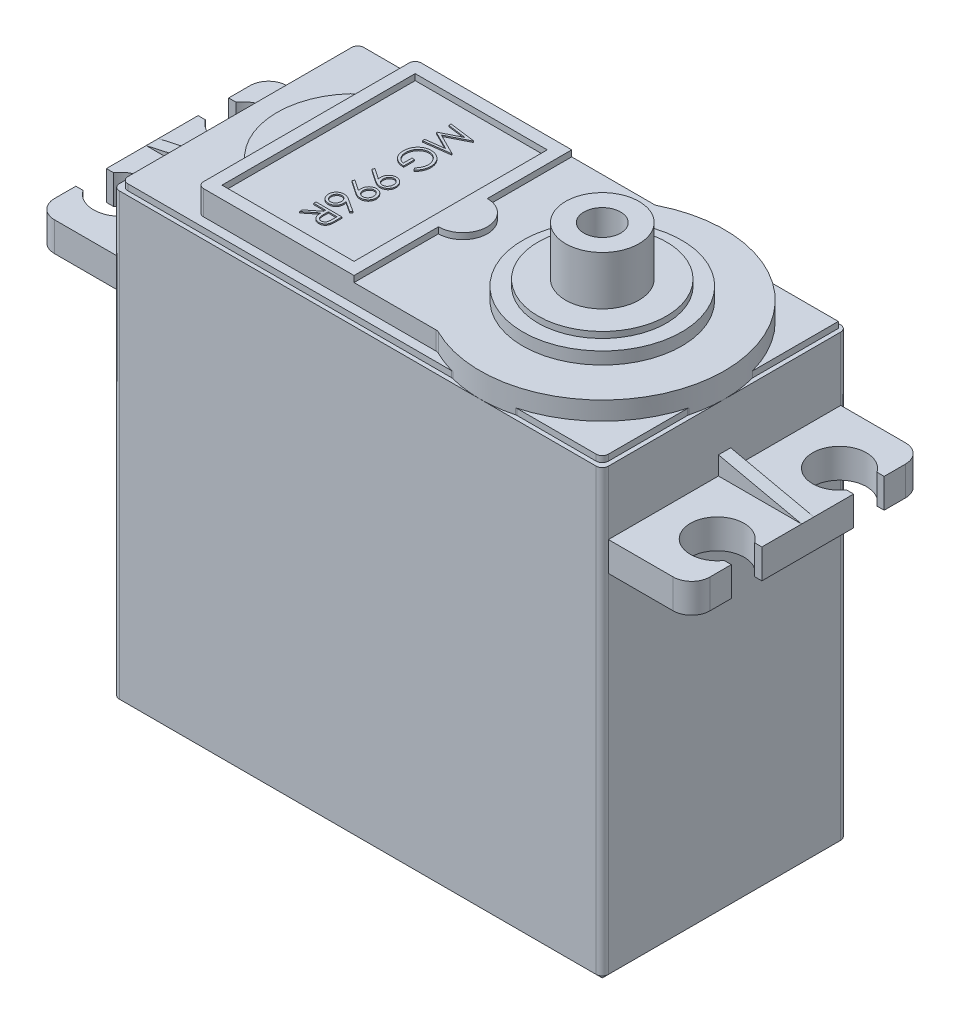
from build123d import *

# Parameters (mm, degrees)
SKETCH2_W                 = 40
SKETCH2_H                 = 20
BOSS_EXTRUDE1_DEPTH       = 38
BOSS_EXTRUDE2_DEPTH       = 2
BOSS_EXTRUDE3_DEPTH       = 0.5
SKETCH5_W                 = 12.8
SKETCH5_H                 = 17.8
SKETCH5_W_2               = 10.8
SKETCH5_H_2               = 15.8
BOSS_EXTRUDE4_DEPTH       = 0.5
BOSS_EXTRUDE5_DEPTH       = 0.5
SKETCH7_R                 = 6.5
BOSS_EXTRUDE6_DEPTH       = 1
SKETCH8_R                 = 5.25
BOSS_EXTRUDE7_DEPTH       = 0.5
SKETCH9_R                 = 3
BOSS_EXTRUDE8_DEPTH       = 4
SKETCH10_R                = 1.5
CUT_EXTRUDE1_DEPTH        = 10
CHAMFER1_SIZE             = 2
SKETCH11_R                = 2.828427125
CUT_EXTRUDE2_DEPTH        = 2
FILLET1_R                 = 0.5
FILLET2_R                 = 0.5
BOSS_EXTRUDE9_DEPTH       = 2.4
BOSS_EXTRUDE10_DEPTH      = 0.5
BOSS_EXTRUDE10_DEPTH_BACK = 0.5
BOSS_EXTRUDE11_DEPTH      = 0.1
FILLET3_R                 = 1.5


with BuildPart() as part:
    # Sketch2 → Boss-Extrude1 (new body)
    with BuildSketch(Plane(origin=(0, 0, 0), x_dir=(1, 0, 0), z_dir=(0, 1, 0))):
        Rectangle(SKETCH2_W, SKETCH2_H)
    extrude(amount=BOSS_EXTRUDE1_DEPTH)

    # Sketch3 → Boss-Extrude2 (add)
    with BuildSketch(Plane(origin=(0, 38, 0), x_dir=(1, 0, 0), z_dir=(0, 1, 0))):
        with BuildLine():
            ThreePointArc((5.440394754, 8.9), (0, 0), (5.440394754, -8.9))
            Line((5.440394754, -8.9), (5.440394754, 8.9))
        make_face()
        with BuildLine():
            Line((5.440394754, 8.9), (5.440394754, -8.9))
            ThreePointArc((5.440394754, -8.9), (15.215551147, -8.532175938), (20, 0))
            ThreePointArc((20, 0), (15.215551147, 8.532175938), (5.440394754, 8.9))
        make_face()
        with BuildLine():
            Line((-14.2, -5), (-14.2, -8.9))
            Line((-14.2, -8.9), (5.440394754, -8.9))
            ThreePointArc((5.440394754, -8.9), (0, 0), (5.440394754, 8.9))
            Line((5.440394754, 8.9), (-14.2, 8.9))
            Line((-14.2, 8.9), (-14.2, 5))
            ThreePointArc((-14.2, 5), (-7.418581742, 5.77726026), (-3.783333333, 0))
            ThreePointArc((-3.783333333, 0), (-7.418581742, -5.77726026), (-14.2, -5))
        make_face()
        with BuildLine():
            ThreePointArc((-14.2, 5), (-16.6, 0), (-14.2, -5))
            Line((-14.2, -5), (-14.2, 5))
        make_face()
        with BuildLine():
            Line((-14.2, 5), (-14.2, -5))
            ThreePointArc((-14.2, -5), (-7.418581742, -5.77726026), (-3.783333333, 0))
            ThreePointArc((-3.783333333, 0), (-7.418581742, 5.77726026), (-14.2, 5))
        make_face()
    extrude(amount=BOSS_EXTRUDE2_DEPTH)

    # Sketch4 → Boss-Extrude3 (add)
    with BuildSketch(Plane(origin=(0, 38, 0), x_dir=(1, 0, 0), z_dir=(0, 1, 0))):
        Polygon((-19.65, 9.65), (-19.65, -9.65), (10, -9.65), (19.65, -9.65), (19.65, 0), (19.65, 9.65), (10, 9.65), align=None)
    extrude(amount=BOSS_EXTRUDE3_DEPTH)

    # Sketch5 → Boss-Extrude4 (add)
    with BuildSketch(Plane(origin=(0, 40, 0), x_dir=(1, 0, 0), z_dir=(0, 1, 0))):
        with Locations((-7.8, 0)):
            Rectangle(SKETCH5_W, SKETCH5_H)
        with Locations((-7.8, 0)):
            Rectangle(SKETCH5_W_2, SKETCH5_H_2, mode=Mode.SUBTRACT)
    extrude(amount=BOSS_EXTRUDE4_DEPTH)

    # Sketch6 → Boss-Extrude5 (add)
    with BuildSketch(Plane(origin=(0, 40, 0), x_dir=(1, 0, 0), z_dir=(0, 1, 0))):
        with BuildLine():
            ThreePointArc((0.6, 0), (0.014213562, 1.414213562), (-1.4, 2))
            Line((-1.4, 2), (-1.4, -2))
            ThreePointArc((-1.4, -2), (0.014213562, -1.414213562), (0.6, 0))
        make_face()
    extrude(amount=BOSS_EXTRUDE5_DEPTH)

    # Sketch7 → Boss-Extrude6 (add)
    with BuildSketch(Plane(origin=(0, 40, 0), x_dir=(1, 0, 0), z_dir=(0, 1, 0))):
        with Locations((10, 0)):
            Circle(SKETCH7_R)
    extrude(amount=BOSS_EXTRUDE6_DEPTH)

    # Sketch8 → Boss-Extrude7 (add)
    with BuildSketch(Plane(origin=(0, 41, 0), x_dir=(1, 0, 0), z_dir=(0, 1, 0))):
        with Locations((10, 0)):
            Circle(SKETCH8_R)
    extrude(amount=BOSS_EXTRUDE7_DEPTH)

    # Sketch9 → Boss-Extrude8 (add)
    with BuildSketch(Plane(origin=(0, 41.5, 0), x_dir=(1, 0, 0), z_dir=(0, 1, 0))):
        with Locations((10, 0)):
            Circle(SKETCH9_R)
    extrude(amount=BOSS_EXTRUDE8_DEPTH)

    # Sketch10 → Cut-Extrude1 (cut)
    with BuildSketch(Plane(origin=(0, 45.5, 0), x_dir=(1, 0, 0), z_dir=(0, 1, 0))):
        with Locations((10, 0)):
            Circle(SKETCH10_R)
    extrude(amount=-CUT_EXTRUDE1_DEPTH, mode=Mode.SUBTRACT)

    # Chamfer1
    chamfer1_edges = [part.edges().sort_by_distance(p)[0] for p in [
        (0, 0, 10),
        (-20, 0, 0),
        (0, 0, -10),
        (20, 0, 0),
    ]]
    chamfer(chamfer1_edges, length=CHAMFER1_SIZE)

    # Sketch11 → Cut-Extrude2 (cut)
    with BuildSketch(Plane.XZ):
        with Locations((-20, 10)):
            Circle(SKETCH11_R)
        with Locations((20, 10)):
            Circle(SKETCH11_R)
        with Locations((20, -10)):
            Circle(SKETCH11_R)
        with Locations((-20, -10)):
            Circle(SKETCH11_R)
    extrude(amount=-CUT_EXTRUDE2_DEPTH, mode=Mode.SUBTRACT)

    # Fillet1
    fillet1_edges = [part.edges().sort_by_distance(p)[0] for p in [
        (20, 20, 10),
        (-20, 20, 10),
        (-20, 20, -10),
        (20, 20, -10),
    ]]
    fillet(fillet1_edges, radius=FILLET1_R)

    # Fillet2
    fillet2_edges = [part.edges().sort_by_distance(p)[0] for p in [
        (5.440394754, 39.25, 8.9),
        (5.440394754, 39.25, -8.9),
        (-14.2, 39.5, -8.9),
        (-14.2, 39.25, -5),
        (-14.2, 39.25, 5),
        (-14.2, 39.5, 8.9),
        (7.377501192, 38.25, 9.65),
        (7.377501192, 38.25, -9.65),
        (19.65, 38.25, 2.622498808),
        (12.622498808, 38.25, 9.65),
        (-19.65, 38.25, 9.65),
        (19.65, 38.25, 9.65),
        (-19.65, 38.25, -9.65),
    ]]
    fillet(fillet2_edges, radius=FILLET2_R)

    # Sketch13 → Boss-Extrude9 (add)
    with BuildSketch(Plane(origin=(0, 32.8, 0), x_dir=(1, 0, 0), z_dir=(0, 1, 0))):
        with BuildLine():
            Line((-26.210386699, -6.25), (-26.8, -6.25))
            Line((-26.8, -6.25), (-26.8, -9.5))
            Line((-26.8, -9.5), (-20, -9.5))
            Line((-20, -9.5), (-20, 9.5))
            Line((-20, 9.5), (-26.8, 9.5))
            Line((-26.8, 9.5), (-26.8, 6.25))
            Line((-26.8, 6.25), (-26.210386699, 6.25))
            ThreePointArc((-26.210386699, 6.25), (-23.745343883, 7.100339346), (-22.2, 5))
            ThreePointArc((-22.2, 5), (-22.844365081, 3.444365081), (-24.4, 2.8))
            Line((-24.4, 2.8), (-24.4, -2.8))
            ThreePointArc((-24.4, -2.8), (-22.844365081, -3.444365081), (-22.2, -5))
            ThreePointArc((-22.2, -5), (-23.745343883, -7.100339346), (-26.210386699, -6.25))
        make_face()
        with BuildLine():
            Line((-26.8, 3.75), (-26.8, -3.75))
            Line((-26.8, -3.75), (-26.210386699, -3.75))
            ThreePointArc((-26.210386699, -3.75), (-25.422252415, -3.051924026), (-24.4, -2.8))
            Line((-24.4, -2.8), (-24.4, 2.8))
            ThreePointArc((-24.4, 2.8), (-25.422252415, 3.051924026), (-26.210386699, 3.75))
            Line((-26.210386699, 3.75), (-26.8, 3.75))
        make_face()
        with BuildLine():
            Line((26.8, 9.5), (20, 9.5))
            Line((20, 9.5), (20, -9.5))
            Line((20, -9.5), (26.8, -9.5))
            Line((26.8, -9.5), (26.8, -6.25))
            Line((26.8, -6.25), (26.210386699, -6.25))
            ThreePointArc((26.210386699, -6.25), (22.451924026, -6.022252415), (24.4, -2.8))
            Line((24.4, -2.8), (24.4, 2.8))
            ThreePointArc((24.4, 2.8), (22.451924026, 6.022252415), (26.210386699, 6.25))
            Line((26.210386699, 6.25), (26.8, 6.25))
            Line((26.8, 6.25), (26.8, 9.5))
        make_face()
        with BuildLine():
            Line((26.8, -3.75), (26.8, 3.75))
            Line((26.8, 3.75), (26.210386699, 3.75))
            ThreePointArc((26.210386699, 3.75), (25.422252415, 3.051924026), (24.4, 2.8))
            Line((24.4, 2.8), (24.4, -2.8))
            ThreePointArc((24.4, -2.8), (25.422252415, -3.051924026), (26.210386699, -3.75))
            Line((26.210386699, -3.75), (26.8, -3.75))
        make_face()
    extrude(amount=-BOSS_EXTRUDE9_DEPTH)

    # Sketch14 → Boss-Extrude10 (add, two sides)
    with BuildSketch(Plane.XY) as boss_extrude10_sk:
        Polygon((20, 34.3), (26.8, 32.8), (20, 32.8), align=None)
        Polygon((-20, 32.8), (-26.8, 32.8), (-20, 34.3), align=None)
    extrude(amount=BOSS_EXTRUDE10_DEPTH)
    extrude(boss_extrude10_sk.sketch, amount=-BOSS_EXTRUDE10_DEPTH_BACK)

    # Sketch15 → Boss-Extrude11 (add)
    with BuildSketch(Plane(origin=(0, 40, 0), x_dir=(1, 0, 0), z_dir=(0, 1, 0))):
        Polygon((-8.561548725, 6.200747863), (-6.444882058, 5.921324119), (-6.444882058, 5.894187366), (-8.181634195, 5.020299145), (-6.444882058, 4.148530983), (-6.444882058, 4.120970219), (-8.561548725, 3.839850427), (-8.561548725, 4.030655716), (-7.038498511, 4.233333333), (-8.561548725, 4.997402511), (-8.561548725, 5.040227698), (-7.035106417, 5.807264957), (-8.561548725, 6.009518563), align=None)
        with BuildLine():
            Line((-6.806140071, 1.424679487), (-6.960480348, 1.5875))
            add(Edge.make_bspline(
                [(-6.960480348, 1.5875), (-6.932810967, 1.617141776), (-6.878278885, 1.675561142), (-6.80662192, 1.770186257), (-6.746314601, 1.86944475), (-6.696391634, 1.971860294), (-6.656919261, 2.075604624), (-6.628967869, 2.179013721), (-6.610865102, 2.280971117), (-6.608747952, 2.348670327), (-6.607702571, 2.382098024)],
                knots=[0, 0, 0, 0, 0.000121591, 0.000239637, 0.000355333, 0.000469492, 0.000581004, 0.000687772, 0.00079052, 0.000890738, 0.000890738, 0.000890738, 0.000890738], degree=3))
            add(Edge.make_bspline(
                [(-6.607702571, 2.382098024), (-6.607953073, 2.402608227), (-6.608453428, 2.44357544), (-6.61482467, 2.504429471), (-6.624016441, 2.564637149), (-6.637179143, 2.623990847), (-6.654275269, 2.682726549), (-6.674916288, 2.740713594), (-6.699763682, 2.797840051), (-6.728091949, 2.853805452), (-6.759017048, 2.908338456), (-6.793507197, 2.959627677), (-6.830503248, 3.007883988), (-6.87048222, 3.052777152), (-6.912808712, 3.094881359), (-6.958058639, 3.133649558), (-7.005903564, 3.169276199), (-7.056339068, 3.201350739), (-7.108218655, 3.229989232), (-7.161069102, 3.255321041), (-7.214835326, 3.276378841), (-7.269205905, 3.29385362), (-7.324294202, 3.307543871), (-7.380101658, 3.317338355), (-7.436818766, 3.322821216), (-7.474795627, 3.32377344), (-7.493887133, 3.324252137)],
                knots=[0, 0, 0, 0, 6.1505e-05, 0.000122851, 0.00018336, 0.000244159, 0.000305081, 0.000366775, 0.000428686, 0.000491831, 0.000554889, 0.000616629, 0.000677098, 0.00073717, 0.000796836, 0.000856071, 0.000915773, 0.000975643, 0.001035235, 0.001093461, 0.001151334, 0.001208323, 0.001264679, 0.001321492, 0.001378154, 0.001435435, 0.001435435, 0.001435435, 0.001435435], degree=3))
            add(Edge.make_bspline(
                [(-7.493887133, 3.324252137), (-7.513402204, 3.323791035), (-7.552379057, 3.32287009), (-7.610569839, 3.317088711), (-7.667784816, 3.306022676), (-7.724660506, 3.292391015), (-7.780460079, 3.273405367), (-7.835808383, 3.25102033), (-7.890199064, 3.224186229), (-7.943301216, 3.193217907), (-7.995020793, 3.159233867), (-8.04374052, 3.12116956), (-8.09010677, 3.080734487), (-8.133090712, 3.0364576), (-8.173841918, 2.989758138), (-8.211237688, 2.939241006), (-8.245998327, 2.885899516), (-8.277685746, 2.829652298), (-8.305993766, 2.771109663), (-8.331166312, 2.71108296), (-8.35189715, 2.649380424), (-8.368793051, 2.586326321), (-8.382642278, 2.521995819), (-8.391551921, 2.456062376), (-8.398017328, 2.389010786), (-8.398490052, 2.343811708), (-8.398728212, 2.321040331)],
                knots=[0, 0, 0, 0, 5.8552e-05, 0.000116944, 0.000175159, 0.000233263, 0.00029226, 0.000351786, 0.000412277, 0.000474022, 0.000536114, 0.000597773, 0.00065936, 0.000720526, 0.000782752, 0.000845167, 0.00090891, 0.000973652, 0.001038697, 0.001103897, 0.001168794, 0.0012338, 0.001299662, 0.001366043, 0.001433299, 0.001501586, 0.001501586, 0.001501586, 0.001501586], degree=3))
            add(Edge.make_bspline(
                [(-8.398728212, 2.321040331), (-8.398154549, 2.293597235), (-8.397028069, 2.239708258), (-8.388258845, 2.160492649), (-8.374562931, 2.084411739), (-8.354505447, 2.011679341), (-8.328921843, 1.942210858), (-8.298081601, 1.875752074), (-8.260802879, 1.81282455), (-8.218724818, 1.753245395), (-8.171855725, 1.698344593), (-8.121238623, 1.648893856), (-8.067368749, 1.605427514), (-8.009770291, 1.568307131), (-7.949364291, 1.536328164), (-7.885075037, 1.510826334), (-7.817631427, 1.491099952), (-7.771005497, 1.483030405), (-7.74744616, 1.478952991)],
                knots=[0, 0, 0, 0, 8.2312e-05, 0.000161633, 0.00023881, 0.000314005, 0.000387652, 0.000460682, 0.000533475, 0.00060677, 0.000679251, 0.000749715, 0.000818782, 0.000886525, 0.000954992, 0.001023493, 0.001093676, 0.001165357, 0.001165357, 0.001165357, 0.001165357], degree=3))
            Line((-7.74744616, 1.478952991), (-7.74744616, 2.184508547))
            Line((-7.74744616, 2.184508547), (-7.530352143, 2.184508547))
            Line((-7.530352143, 2.184508547), (-7.530352143, 1.288995726))
            add(Edge.make_bspline(
                [(-7.530352143, 1.288995726), (-7.570815244, 1.290027359), (-7.65000884, 1.292046449), (-7.765500385, 1.306209317), (-7.874582314, 1.329079303), (-7.977369505, 1.360321492), (-8.073716297, 1.400765114), (-8.163720511, 1.449976119), (-8.246800694, 1.508742116), (-8.323635092, 1.574969859), (-8.392172282, 1.649295072), (-8.452410159, 1.729709428), (-8.503151264, 1.816345785), (-8.544432712, 1.909122192), (-8.576650795, 2.00773493), (-8.599493606, 2.112412189), (-8.613179345, 2.223012014), (-8.614927941, 2.298810861), (-8.615822229, 2.33757679)],
                knots=[0, 0, 0, 0, 0.000121374, 0.000237551, 0.000348487, 0.000455382, 0.000559331, 0.000661426, 0.000762474, 0.000864069, 0.000965184, 0.001065167, 0.00116494, 0.001265725, 0.001369239, 0.001475615, 0.00158669, 0.001702963, 0.001702963, 0.001702963, 0.001702963], degree=3))
            add(Edge.make_bspline(
                [(-8.615822229, 2.33757679), (-8.615478046, 2.361471014), (-8.614799206, 2.408598126), (-8.609974811, 2.478200735), (-8.602547986, 2.545884249), (-8.591332602, 2.611638806), (-8.577595644, 2.67570628), (-8.560005105, 2.737766696), (-8.539643558, 2.798056463), (-8.516483794, 2.856668769), (-8.489649506, 2.913071614), (-8.459828914, 2.967516222), (-8.427175787, 3.020303546), (-8.391125418, 3.071074012), (-8.351947454, 3.120092155), (-8.30956337, 3.167041904), (-8.26410274, 3.212186097), (-8.231821149, 3.240465044), (-8.215555135, 3.254714209)],
                knots=[0, 0, 0, 0, 7.1678e-05, 0.000141372, 0.000209221, 0.000275861, 0.000341398, 0.000405698, 0.000469255, 0.000532244, 0.000594645, 0.000656504, 0.000718394, 0.000780746, 0.000843191, 0.00090654, 0.000970402, 0.001035264, 0.001035264, 0.001035264, 0.001035264], degree=3))
            add(Edge.make_bspline(
                [(-8.215555135, 3.254714209), (-8.189749549, 3.275388559), (-8.138566725, 3.316394084), (-8.056561044, 3.369176589), (-7.971651348, 3.414171723), (-7.883601263, 3.450679882), (-7.792493148, 3.479187201), (-7.698443425, 3.499631935), (-7.601330981, 3.511610629), (-7.535614369, 3.513336339), (-7.502367368, 3.514209402)],
                knots=[0, 0, 0, 0, 9.9144e-05, 0.000196643, 0.000292047, 0.000387091, 0.000482172, 0.000578064, 0.000675465, 0.000775198, 0.000775198, 0.000775198, 0.000775198], degree=3))
            add(Edge.make_bspline(
                [(-7.502367368, 3.514209402), (-7.477471848, 3.513886652), (-7.427997216, 3.513245255), (-7.354540612, 3.505501702), (-7.282406505, 3.494325229), (-7.211528085, 3.478136556), (-7.142220096, 3.456836256), (-7.073949701, 3.43125565), (-7.006990819, 3.401292598), (-6.941932978, 3.366330162), (-6.878813215, 3.328261658), (-6.81956397, 3.285499792), (-6.76316018, 3.240150202), (-6.710623529, 3.190930726), (-6.66172523, 3.138120193), (-6.616284106, 3.082011022), (-6.574184016, 3.022630631), (-6.536102939, 2.959773118), (-6.501895232, 2.89438185), (-6.471905615, 2.826612167), (-6.447120454, 2.756485136), (-6.426090601, 2.684526037), (-6.410539062, 2.610190217), (-6.399261012, 2.534017106), (-6.391543887, 2.455609658), (-6.390923247, 2.402610726), (-6.390608554, 2.375737847)],
                knots=[0, 0, 0, 0, 7.4656e-05, 0.000148364, 0.000221349, 0.000293556, 0.000366254, 0.000438709, 0.000512156, 0.000586133, 0.000660162, 0.000733112, 0.00080516, 0.000877157, 0.000948865, 0.001020914, 0.001093618, 0.001167064, 0.001241218, 0.001314881, 0.001389181, 0.001464197, 0.001539625, 0.001616801, 0.001695151, 0.001775741, 0.001775741, 0.001775741, 0.001775741], degree=3))
            add(Edge.make_bspline(
                [(-6.390608554, 2.375737847), (-6.390958132, 2.353822178), (-6.391651306, 2.31036598), (-6.396480839, 2.245703717), (-6.404050769, 2.182168228), (-6.414636047, 2.119440796), (-6.428638655, 2.057760259), (-6.445703782, 1.996939746), (-6.465461901, 1.937094288), (-6.489044269, 1.878295081), (-6.515806248, 1.820142357), (-6.545931764, 1.762313966), (-6.579934434, 1.705007169), (-6.617915639, 1.648122675), (-6.659222939, 1.59130175), (-6.705037781, 1.535443133), (-6.753553448, 1.479198495), (-6.788437435, 1.443032636), (-6.806140071, 1.424679487)],
                knots=[0, 0, 0, 0, 6.5744e-05, 0.000130362, 0.00019442, 0.000257645, 0.000321112, 0.000384073, 0.000447093, 0.000510083, 0.00057402, 0.000639071, 0.000705608, 0.000773816, 0.000844207, 0.000916255, 0.000990487, 0.00106697, 0.00106697, 0.00106697, 0.00106697], degree=3))
        make_face()
        with BuildLine():
            Line((-8.615822229, -0.230662393), (-8.510243303, -0.078866186))
            Line((-8.510243303, -0.078866186), (-7.649923457, -0.667394498))
            add(Edge.make_bspline(
                [(-7.649923457, -0.667394498), (-7.654515453, -0.629844386), (-7.663557348, -0.555906123), (-7.66521842, -0.481437495), (-7.666035904, -0.444788328)],
                knots=[0, 0, 0, 0, 0.00011341, 0.000223311, 0.000223311, 0.000223311, 0.000223311], degree=3))
            add(Edge.make_bspline(
                [(-7.666035904, -0.444788328), (-7.665465089, -0.422568752), (-7.664344629, -0.378953667), (-7.655513825, -0.314821021), (-7.641758816, -0.253105896), (-7.621709949, -0.194043366), (-7.596086972, -0.137686046), (-7.564874842, -0.083837274), (-7.527957379, -0.032568352), (-7.48573141, 0.015517442), (-7.439357742, 0.059248093), (-7.390278343, 0.09820904), (-7.337920379, 0.130588628), (-7.28335261, 0.157486385), (-7.225790547, 0.177885275), (-7.165889245, 0.192739763), (-7.103228871, 0.201885187), (-7.060577958, 0.202973211), (-7.038922523, 0.203525641)],
                knots=[0, 0, 0, 0, 6.6636e-05, 0.000130801, 0.000193854, 0.00025607, 0.00031755, 0.000379295, 0.000442485, 0.000506784, 0.000570971, 0.000633485, 0.000694431, 0.000755303, 0.000815656, 0.000877256, 0.000940218, 0.00100516, 0.00100516, 0.00100516, 0.00100516], degree=3))
            add(Edge.make_bspline(
                [(-7.038922523, 0.203525641), (-7.009308147, 0.202476721), (-6.951181135, 0.200417904), (-6.866252141, 0.183848324), (-6.785947898, 0.156597548), (-6.710479543, 0.118601339), (-6.640932686, 0.070743674), (-6.578274147, 0.013225622), (-6.523395116, -0.053602966), (-6.476221221, -0.128219711), (-6.438281485, -0.208866538), (-6.410317718, -0.293332822), (-6.393868951, -0.380971361), (-6.391700359, -0.440339428), (-6.390608554, -0.470229033)],
                knots=[0, 0, 0, 0, 8.879e-05, 0.000174276, 0.000258483, 0.000342486, 0.000426933, 0.00051096, 0.000596792, 0.000685605, 0.000775132, 0.000863494, 0.000951897, 0.001041533, 0.001041533, 0.001041533, 0.001041533], degree=3))
            add(Edge.make_bspline(
                [(-6.390608554, -0.470229033), (-6.391711389, -0.499554125), (-6.393890488, -0.557497742), (-6.409989707, -0.642817912), (-6.436834093, -0.724608652), (-6.474101775, -0.802226446), (-6.521118713, -0.873720655), (-6.576681277, -0.938257711), (-6.64141553, -0.994108657), (-6.7135508, -1.041177485), (-6.791062879, -1.078955938), (-6.871969886, -1.106214213), (-6.955692458, -1.122993647), (-7.012415768, -1.125108102), (-7.041042581, -1.126175214)],
                knots=[0, 0, 0, 0, 8.7943e-05, 0.000173768, 0.000259449, 0.000345548, 0.00043128, 0.000515444, 0.000600206, 0.00068688, 0.000773164, 0.000858174, 0.000942412, 0.001028239, 0.001028239, 0.001028239, 0.001028239], degree=3))
            add(Edge.make_bspline(
                [(-7.041042581, -1.126175214), (-7.063265591, -1.125471359), (-7.108339407, -1.124043767), (-7.176756075, -1.113788054), (-7.246659676, -1.097177732), (-7.305904252, -1.077910467), (-7.354338889, -1.058180733), (-7.39320891, -1.041205888), (-7.43377282, -1.021448467), (-7.475732488, -0.997979546), (-7.520191871, -0.973443639), (-7.566180028, -0.945545859), (-7.613953944, -0.915135235), (-7.646154795, -0.893465055), (-7.66264381, -0.882368456)],
                knots=[0, 0, 0, 0, 6.6656e-05, 0.000135195, 0.000207085, 0.000282039, 0.000321802, 0.00036395, 0.000409271, 0.000457087, 0.000508155, 0.000561603, 0.000618416, 0.000678039, 0.000678039, 0.000678039, 0.000678039], degree=3))
            Line((-7.66264381, -0.882368456), (-8.615822229, -0.230662393))
        make_face()
        with BuildLine():
            add(Edge.make_bspline(
                [(-7.448941887, -0.479981303), (-7.448482036, -0.496814255), (-7.447586862, -0.529582289), (-7.442138416, -0.577586655), (-7.432477957, -0.622897959), (-7.418616989, -0.665637239), (-7.401891289, -0.706233032), (-7.380596421, -0.744040525), (-7.355186361, -0.779091361), (-7.326635542, -0.811620251), (-7.294915427, -0.840506098), (-7.261715748, -0.866234502), (-7.22689077, -0.888103036), (-7.190004368, -0.905377018), (-7.151954438, -0.919579594), (-7.112128232, -0.92938763), (-7.070733247, -0.934821013), (-7.04261263, -0.935747251), (-7.028322229, -0.936217949)],
                knots=[0, 0, 0, 0, 5.0502e-05, 9.831e-05, 0.000144716, 0.000189235, 0.000232941, 0.000276225, 0.000319059, 0.000362617, 0.000405829, 0.000447554, 0.0004885, 0.000528897, 0.000569542, 0.000610163, 0.00065166, 0.000694538, 0.000694538, 0.000694538, 0.000694538], degree=3))
            add(Edge.make_bspline(
                [(-7.028322229, -0.936217949), (-7.014025829, -0.935812995), (-6.985853018, -0.935014984), (-6.944397196, -0.92861166), (-6.904666744, -0.917349802), (-6.86645419, -0.902229162), (-6.830035937, -0.882347874), (-6.795174436, -0.858401984), (-6.761438784, -0.830511008), (-6.730566414, -0.797779052), (-6.701740554, -0.762562584), (-6.676751595, -0.724697037), (-6.655420763, -0.685121664), (-6.637969282, -0.64380493), (-6.624323924, -0.600660833), (-6.614518181, -0.55568704), (-6.609091887, -0.508663884), (-6.608171575, -0.476743724), (-6.607702571, -0.460476763)],
                knots=[0, 0, 0, 0, 4.2878e-05, 8.4496e-05, 0.000125441, 0.000166541, 0.000207522, 0.000249625, 0.000293274, 0.000338556, 0.00038438, 0.000429656, 0.000474427, 0.000519079, 0.000564003, 0.000609994, 0.00065696, 0.000705767, 0.000705767, 0.000705767, 0.000705767], degree=3))
            add(Edge.make_bspline(
                [(-6.607702571, -0.460476763), (-6.608172247, -0.444351233), (-6.609093748, -0.412713077), (-6.614508827, -0.366108536), (-6.624386378, -0.321436711), (-6.637975872, -0.278425438), (-6.65532584, -0.237195791), (-6.676751434, -0.197935219), (-6.701874032, -0.160464245), (-6.730529707, -0.12525782), (-6.761586997, -0.092596047), (-6.795027032, -0.06421388), (-6.830054393, -0.040323477), (-6.866449285, -0.020414623), (-6.904668053, -0.005301316), (-6.944396841, 0.005962506), (-6.985853111, 0.012365303), (-7.01402586, 0.013163386), (-7.028322229, 0.013568376)],
                knots=[0, 0, 0, 0, 4.8384e-05, 9.4929e-05, 0.000140505, 0.000185429, 0.000230081, 0.000274479, 0.000319402, 0.000365227, 0.000410509, 0.00045443, 0.000496534, 0.000537514, 0.000578615, 0.00061956, 0.000661178, 0.000704055, 0.000704055, 0.000704055, 0.000704055], degree=3))
            add(Edge.make_bspline(
                [(-7.028322229, 0.013568376), (-7.042623759, 0.013201935), (-7.070828993, 0.012479246), (-7.112271145, 0.005507678), (-7.151996862, -0.006151091), (-7.190392413, -0.021765675), (-7.227084442, -0.042328541), (-7.261898989, -0.067561535), (-7.295230714, -0.097137746), (-7.326561742, -0.130661808), (-7.355319486, -0.1673516), (-7.380435479, -0.206538204), (-7.401645957, -0.24754701), (-7.418664794, -0.290522377), (-7.432339467, -0.335145823), (-7.442120611, -0.381818402), (-7.447534601, -0.430385765), (-7.448468291, -0.463290849), (-7.448941887, -0.479981303)],
                knots=[0, 0, 0, 0, 4.2878e-05, 8.4563e-05, 0.000125624, 0.000166884, 0.000208644, 0.000251478, 0.000295634, 0.000342131, 0.000388951, 0.000435292, 0.000481564, 0.000527232, 0.000573775, 0.000621424, 0.000670075, 0.000720153, 0.000720153, 0.000720153, 0.000720153], degree=3))
        make_face(mode=Mode.SUBTRACT)
        with BuildLine():
            Line((-8.615822229, -1.858867521), (-8.510243303, -1.707071314))
            Line((-8.510243303, -1.707071314), (-7.649923457, -2.295599626))
            add(Edge.make_bspline(
                [(-7.649923457, -2.295599626), (-7.654515453, -2.258049515), (-7.663557348, -2.184111251), (-7.66521842, -2.109642623), (-7.666035904, -2.072993456)],
                knots=[0, 0, 0, 0, 0.00011341, 0.000223311, 0.000223311, 0.000223311, 0.000223311], degree=3))
            add(Edge.make_bspline(
                [(-7.666035904, -2.072993456), (-7.665465089, -2.05077388), (-7.664344629, -2.007158795), (-7.655513825, -1.943026149), (-7.641758816, -1.881311024), (-7.621709949, -1.822248495), (-7.596086972, -1.765891175), (-7.564874842, -1.712042402), (-7.527957379, -1.66077348), (-7.48573141, -1.612687686), (-7.439357742, -1.568957035), (-7.390278343, -1.529996088), (-7.337920379, -1.497616501), (-7.28335261, -1.470718743), (-7.225790547, -1.450319853), (-7.165889245, -1.435465365), (-7.103228871, -1.426319942), (-7.060577958, -1.425231917), (-7.038922523, -1.424679487)],
                knots=[0, 0, 0, 0, 6.6636e-05, 0.000130801, 0.000193854, 0.00025607, 0.00031755, 0.000379295, 0.000442485, 0.000506784, 0.000570971, 0.000633485, 0.000694431, 0.000755303, 0.000815656, 0.000877256, 0.000940218, 0.00100516, 0.00100516, 0.00100516, 0.00100516], degree=3))
            add(Edge.make_bspline(
                [(-7.038922523, -1.424679487), (-7.009308147, -1.425728407), (-6.951181135, -1.427787225), (-6.866252141, -1.444356804), (-6.785947898, -1.471607581), (-6.710479543, -1.509603789), (-6.640932686, -1.557461454), (-6.578274147, -1.614979506), (-6.523395116, -1.681808094), (-6.476221221, -1.756424839), (-6.438281485, -1.837071666), (-6.410317718, -1.92153795), (-6.393868951, -2.009176489), (-6.391700359, -2.068544556), (-6.390608554, -2.098434161)],
                knots=[0, 0, 0, 0, 8.879e-05, 0.000174276, 0.000258483, 0.000342486, 0.000426933, 0.00051096, 0.000596792, 0.000685605, 0.000775132, 0.000863494, 0.000951897, 0.001041533, 0.001041533, 0.001041533, 0.001041533], degree=3))
            add(Edge.make_bspline(
                [(-6.390608554, -2.098434161), (-6.391711389, -2.127759253), (-6.393890488, -2.18570287), (-6.409989707, -2.271023041), (-6.436834093, -2.35281378), (-6.474101775, -2.430431574), (-6.521118713, -2.501925783), (-6.576681277, -2.566462839), (-6.64141553, -2.622313785), (-6.7135508, -2.669382613), (-6.791062879, -2.707161066), (-6.871969886, -2.734419341), (-6.955692458, -2.751198775), (-7.012415768, -2.75331323), (-7.041042581, -2.754380342)],
                knots=[0, 0, 0, 0, 8.7943e-05, 0.000173768, 0.000259449, 0.000345548, 0.00043128, 0.000515444, 0.000600206, 0.00068688, 0.000773164, 0.000858174, 0.000942412, 0.001028239, 0.001028239, 0.001028239, 0.001028239], degree=3))
            add(Edge.make_bspline(
                [(-7.041042581, -2.754380342), (-7.063265591, -2.753676488), (-7.108339407, -2.752248895), (-7.176756075, -2.741993182), (-7.246659676, -2.72538286), (-7.305904252, -2.706115595), (-7.354338889, -2.686385861), (-7.39320891, -2.669411017), (-7.43377282, -2.649653596), (-7.475732488, -2.626184674), (-7.520191871, -2.601648767), (-7.566180028, -2.573750987), (-7.613953944, -2.543340364), (-7.646154795, -2.521670183), (-7.66264381, -2.510573584)],
                knots=[0, 0, 0, 0, 6.6656e-05, 0.000135195, 0.000207085, 0.000282039, 0.000321802, 0.00036395, 0.000409271, 0.000457087, 0.000508155, 0.000561603, 0.000618416, 0.000678039, 0.000678039, 0.000678039, 0.000678039], degree=3))
            Line((-7.66264381, -2.510573584), (-8.615822229, -1.858867521))
        make_face()
        with BuildLine():
            add(Edge.make_bspline(
                [(-7.448941887, -2.108186432), (-7.448482036, -2.125019383), (-7.447586862, -2.157787417), (-7.442138416, -2.205791783), (-7.432477957, -2.251103087), (-7.418616989, -2.293842367), (-7.401891289, -2.33443816), (-7.380596421, -2.372245654), (-7.355186361, -2.407296489), (-7.326635542, -2.439825379), (-7.294915427, -2.468711226), (-7.261715748, -2.49443963), (-7.22689077, -2.516308164), (-7.190004368, -2.533582146), (-7.151954438, -2.547784723), (-7.112128232, -2.557592758), (-7.070733247, -2.563026141), (-7.04261263, -2.563952379), (-7.028322229, -2.564423077)],
                knots=[0, 0, 0, 0, 5.0502e-05, 9.831e-05, 0.000144716, 0.000189235, 0.000232941, 0.000276225, 0.000319059, 0.000362617, 0.000405829, 0.000447554, 0.0004885, 0.000528897, 0.000569542, 0.000610163, 0.00065166, 0.000694538, 0.000694538, 0.000694538, 0.000694538], degree=3))
            add(Edge.make_bspline(
                [(-7.028322229, -2.564423077), (-7.014025829, -2.564018123), (-6.985853018, -2.563220112), (-6.944397196, -2.556816789), (-6.904666744, -2.54555493), (-6.86645419, -2.53043429), (-6.830035937, -2.510553003), (-6.795174436, -2.486607112), (-6.761438784, -2.458716136), (-6.730566414, -2.42598418), (-6.701740554, -2.390767712), (-6.676751595, -2.352902165), (-6.655420763, -2.313326792), (-6.637969282, -2.272010058), (-6.624323924, -2.228865961), (-6.614518181, -2.183892169), (-6.609091887, -2.136869012), (-6.608171575, -2.104948853), (-6.607702571, -2.088681891)],
                knots=[0, 0, 0, 0, 4.2878e-05, 8.4496e-05, 0.000125441, 0.000166541, 0.000207522, 0.000249625, 0.000293274, 0.000338556, 0.00038438, 0.000429656, 0.000474427, 0.000519079, 0.000564003, 0.000609994, 0.00065696, 0.000705767, 0.000705767, 0.000705767, 0.000705767], degree=3))
            add(Edge.make_bspline(
                [(-6.607702571, -2.088681891), (-6.608172247, -2.072556362), (-6.609093748, -2.040918206), (-6.614508827, -1.994313664), (-6.624386378, -1.949641839), (-6.637975872, -1.906630566), (-6.65532584, -1.865400919), (-6.676751434, -1.826140347), (-6.701874032, -1.788669373), (-6.730529707, -1.753462949), (-6.761586997, -1.720801175), (-6.795027032, -1.692419008), (-6.830054393, -1.668528605), (-6.866449285, -1.648619751), (-6.904668053, -1.633506444), (-6.944396841, -1.622242622), (-6.985853111, -1.615839826), (-7.01402586, -1.615041742), (-7.028322229, -1.614636752)],
                knots=[0, 0, 0, 0, 4.8384e-05, 9.4929e-05, 0.000140505, 0.000185429, 0.000230081, 0.000274479, 0.000319402, 0.000365227, 0.000410509, 0.00045443, 0.000496534, 0.000537514, 0.000578615, 0.00061956, 0.000661178, 0.000704055, 0.000704055, 0.000704055, 0.000704055], degree=3))
            add(Edge.make_bspline(
                [(-7.028322229, -1.614636752), (-7.042623759, -1.615003193), (-7.070828993, -1.615725882), (-7.112271145, -1.62269745), (-7.151996862, -1.634356219), (-7.190392413, -1.649970803), (-7.227084442, -1.67053367), (-7.261898989, -1.695766663), (-7.295230714, -1.725342874), (-7.326561742, -1.758866936), (-7.355319486, -1.795556729), (-7.380435479, -1.834743332), (-7.401645957, -1.875752138), (-7.418664794, -1.918727506), (-7.432339467, -1.963350951), (-7.442120611, -2.010023531), (-7.447534601, -2.058590893), (-7.448468291, -2.091495978), (-7.448941887, -2.108186432)],
                knots=[0, 0, 0, 0, 4.2878e-05, 8.4563e-05, 0.000125624, 0.000166884, 0.000208644, 0.000251478, 0.000295634, 0.000342131, 0.000388951, 0.000435292, 0.000481564, 0.000527232, 0.000573775, 0.000621424, 0.000670075, 0.000720153, 0.000720153, 0.000720153, 0.000720153], degree=3))
        make_face(mode=Mode.SUBTRACT)
        with BuildLine():
            Line((-6.390608554, -4.00267094), (-6.505515738, -4.148954995))
            Line((-6.505515738, -4.148954995), (-7.360747442, -3.589683494))
            add(Edge.make_bspline(
                [(-7.360747442, -3.589683494), (-7.354812393, -3.626918852), (-7.343235409, -3.699550627), (-7.341325604, -3.773069052), (-7.340394878, -3.808897569)],
                knots=[0, 0, 0, 0, 0.000112975, 0.000220371, 0.000220371, 0.000220371, 0.000220371], degree=3))
            add(Edge.make_bspline(
                [(-7.340394878, -3.808897569), (-7.340973098, -3.83041046), (-7.342111307, -3.872757945), (-7.350870588, -3.934931583), (-7.364674346, -3.994675368), (-7.384796139, -4.051741676), (-7.410499944, -4.106335337), (-7.441305832, -4.158769643), (-7.478804506, -4.208058954), (-7.520693312, -4.254838), (-7.567088822, -4.297308673), (-7.616317249, -4.334910383), (-7.668327306, -4.366495157), (-7.723092649, -4.392121291), (-7.780528858, -4.412020908), (-7.840562447, -4.426527722), (-7.903234813, -4.435102999), (-7.945857329, -4.436267463), (-7.96750826, -4.436858974)],
                knots=[0, 0, 0, 0, 6.4518e-05, 0.000127002, 0.00018799, 0.000248202, 0.000308142, 0.000368789, 0.000430271, 0.000493619, 0.000556939, 0.000618676, 0.000679177, 0.000739118, 0.000799729, 0.000861228, 0.000924132, 0.000989074, 0.000989074, 0.000989074, 0.000989074], degree=3))
            add(Edge.make_bspline(
                [(-7.96750826, -4.436858974), (-7.99711171, -4.435754359), (-8.055329948, -4.43358202), (-8.140478861, -4.417768313), (-8.220947324, -4.390477389), (-8.297051566, -4.353965404), (-8.366577328, -4.306593975), (-8.429409974, -4.250456228), (-8.484177856, -4.185021503), (-8.53116094, -4.111839309), (-8.568488941, -4.032633448), (-8.596086294, -3.949583511), (-8.612576414, -3.863399366), (-8.614735314, -3.804868473), (-8.615822229, -3.775400641)],
                knots=[0, 0, 0, 0, 8.879e-05, 0.000174614, 0.000258685, 0.000343073, 0.000427041, 0.000510214, 0.000595069, 0.000682224, 0.000770419, 0.000857038, 0.000944191, 0.001032557, 0.001032557, 0.001032557, 0.001032557], degree=3))
            add(Edge.make_bspline(
                [(-8.615822229, -3.775400641), (-8.614898031, -3.746918345), (-8.613067356, -3.690499904), (-8.596759349, -3.607506818), (-8.570327088, -3.527760785), (-8.5339113, -3.451822351), (-8.487916199, -3.381471818), (-8.432536151, -3.318552584), (-8.368995118, -3.263283559), (-8.29709818, -3.217530585), (-8.22033777, -3.180241787), (-8.139569144, -3.153941459), (-8.056417804, -3.136932968), (-7.999815712, -3.13517817), (-7.971324366, -3.134294872)],
                knots=[0, 0, 0, 0, 8.5378e-05, 0.000169119, 0.000252654, 0.000336857, 0.000421061, 0.000503987, 0.000587553, 0.000672823, 0.000758922, 0.000842859, 0.000927097, 0.001012475, 0.001012475, 0.001012475, 0.001012475], degree=3))
            add(Edge.make_bspline(
                [(-7.971324366, -3.134294872), (-7.949533912, -3.135061981), (-7.905061767, -3.136627574), (-7.83751262, -3.145970856), (-7.768666184, -3.163107575), (-7.710303241, -3.181653251), (-7.661968151, -3.20005616), (-7.623799206, -3.21711976), (-7.583491576, -3.236198945), (-7.541807919, -3.258562406), (-7.497557243, -3.28226948), (-7.452378286, -3.309962032), (-7.404620973, -3.338859636), (-7.372824895, -3.360029284), (-7.356507325, -3.370893429)],
                knots=[0, 0, 0, 0, 6.5386e-05, 0.000133446, 0.000204098, 0.000277985, 0.000317042, 0.00035919, 0.000403379, 0.000450795, 0.000501081, 0.000553946, 0.000609724, 0.000668526, 0.000668526, 0.000668526, 0.000668526], degree=3))
            Line((-7.356507325, -3.370893429), (-6.390608554, -4.00267094))
        make_face()
        with BuildLine():
            add(Edge.make_bspline(
                [(-7.557488895, -3.769040465), (-7.55796566, -3.752916661), (-7.558901067, -3.72128189), (-7.564184256, -3.674927657), (-7.574194451, -3.63117484), (-7.587142868, -3.589523709), (-7.604773044, -3.550408379), (-7.625934253, -3.513382659), (-7.651093547, -3.478813954), (-7.679970407, -3.447309348), (-7.711124571, -3.418380339), (-7.744693386, -3.393496667), (-7.779651265, -3.372008605), (-7.81632677, -3.354543422), (-7.854696374, -3.340941894), (-7.89458613, -3.331103581), (-7.936262846, -3.325628189), (-7.964524888, -3.324717281), (-7.978956577, -3.324252137)],
                knots=[0, 0, 0, 0, 4.8384e-05, 9.4929e-05, 0.000139677, 0.000182856, 0.000225563, 0.000268111, 0.000310601, 0.000353527, 0.000396139, 0.000437947, 0.00047867, 0.000519067, 0.000559568, 0.000600601, 0.000642098, 0.000685399, 0.000685399, 0.000685399, 0.000685399], degree=3))
            add(Edge.make_bspline(
                [(-7.978956577, -3.324252137), (-7.99325864, -3.324631912), (-8.021302855, -3.325376596), (-8.062639556, -3.332107166), (-8.102382527, -3.342461577), (-8.140560837, -3.357617691), (-8.176966227, -3.37662789), (-8.211857297, -3.400022036), (-8.245258129, -3.427404009), (-8.276326473, -3.45923501), (-8.304823113, -3.493561658), (-8.330196575, -3.529864362), (-8.351503498, -3.568027694), (-8.3683483, -3.608269417), (-8.382144594, -3.650026115), (-8.391859881, -3.693616336), (-8.397350919, -3.739078381), (-8.398263088, -3.769873979), (-8.398728212, -3.785576923)],
                knots=[0, 0, 0, 0, 4.2878e-05, 8.4077e-05, 0.000125319, 0.00016587, 0.000207025, 0.000248302, 0.00029168, 0.000336355, 0.000381523, 0.000425396, 0.00046905, 0.000512366, 0.000556078, 0.000600827, 0.000646109, 0.000693222, 0.000693222, 0.000693222, 0.000693222], degree=3))
            add(Edge.make_bspline(
                [(-8.398728212, -3.785576923), (-8.398263125, -3.801279893), (-8.397351027, -3.832075541), (-8.391859471, -3.877537221), (-8.3821461, -3.921128794), (-8.368342841, -3.962880578), (-8.351523748, -4.003140438), (-8.330063063, -4.041337176), (-8.304977385, -4.077986475), (-8.276277427, -4.112290604), (-8.24543368, -4.144254649), (-8.211554876, -4.170995277), (-8.177243536, -4.195128497), (-8.140415763, -4.213408567), (-8.10240551, -4.228733473), (-8.062633399, -4.239035642), (-8.021304467, -4.24578014), (-7.993259184, -4.24652291), (-7.978956577, -4.246901709)],
                knots=[0, 0, 0, 0, 4.7113e-05, 9.2395e-05, 0.000137144, 0.000180856, 0.000224172, 0.000267826, 0.000312048, 0.000357217, 0.000401891, 0.000445001, 0.000486515, 0.000527475, 0.000568026, 0.000609268, 0.000650467, 0.000693345, 0.000693345, 0.000693345, 0.000693345], degree=3))
            add(Edge.make_bspline(
                [(-7.978956577, -4.246901709), (-7.964504386, -4.246572792), (-7.936139434, -4.245927234), (-7.894623679, -4.238484223), (-7.854372005, -4.228431197), (-7.816291144, -4.212184586), (-7.779328009, -4.192833546), (-7.744539033, -4.168181593), (-7.710938638, -4.139917525), (-7.679763788, -4.107184991), (-7.651248732, -4.071574925), (-7.626079417, -4.033706215), (-7.604837009, -3.994089801), (-7.587113233, -3.952763953), (-7.574322825, -3.909255661), (-7.564251581, -3.864267211), (-7.55889217, -3.817223242), (-7.557962611, -3.78530596), (-7.557488895, -3.769040465)],
                knots=[0, 0, 0, 0, 4.3301e-05, 8.4986e-05, 0.000126229, 0.000167489, 0.000208842, 0.000251186, 0.000295108, 0.00034039, 0.000386545, 0.000431821, 0.000476592, 0.000521244, 0.000566447, 0.000612438, 0.000659404, 0.000708211, 0.000708211, 0.000708211, 0.000708211], degree=3))
        make_face(mode=Mode.SUBTRACT)
        with BuildLine():
            Line((-6.444882058, -4.843910256), (-6.444882058, -5.267497997))
            add(Edge.make_bspline(
                [(-6.444882058, -5.267497997), (-6.44497615, -5.295765251), (-6.445156818, -5.350041509), (-6.446164208, -5.427797725), (-6.449051557, -5.498450303), (-6.451536271, -5.561962301), (-6.456067112, -5.618332554), (-6.460397599, -5.667733916), (-6.466066432, -5.709938857), (-6.47133114, -5.735487538), (-6.473714857, -5.747055288)],
                knots=[0, 0, 0, 0, 8.4803e-05, 0.000162832, 0.000233264, 0.000296935, 0.000353488, 0.000402894, 0.000445708, 0.000481133, 0.000481133, 0.000481133, 0.000481133], degree=3))
            add(Edge.make_bspline(
                [(-6.473714857, -5.747055288), (-6.47754061, -5.762541472), (-6.485110501, -5.793183477), (-6.501118557, -5.83729694), (-6.519612907, -5.879351155), (-6.541503811, -5.919188304), (-6.566409445, -5.956812082), (-6.594475323, -5.992166157), (-6.625844373, -6.025048399), (-6.659715564, -6.055711822), (-6.69638443, -6.083507227), (-6.735316805, -6.107560514), (-6.776269191, -6.128157222), (-6.819384199, -6.144600194), (-6.864297363, -6.157828061), (-6.911400858, -6.167158117), (-6.960484112, -6.172752647), (-6.993962441, -6.173322278), (-7.010937747, -6.173611111)],
                knots=[0, 0, 0, 0, 4.7825e-05, 9.463e-05, 0.000140566, 0.000185539, 0.000230816, 0.000275779, 0.000320768, 0.000367003, 0.000412712, 0.000458601, 0.000504111, 0.000550018, 0.000596845, 0.00064441, 0.000693904, 0.000744813, 0.000744813, 0.000744813, 0.000744813], degree=3))
            add(Edge.make_bspline(
                [(-7.010937747, -6.173611111), (-7.039140914, -6.17272274), (-7.094172598, -6.170989298), (-7.174037535, -6.154826651), (-7.248539397, -6.128353458), (-7.317574504, -6.091867892), (-7.379833545, -6.045426457), (-7.434332736, -5.989614413), (-7.480359785, -5.924716787), (-7.511938398, -5.864017709), (-7.532257431, -5.810373886), (-7.546625747, -5.766081324), (-7.557539871, -5.717728938), (-7.567459284, -5.666010417), (-7.575028594, -5.610526282), (-7.580404242, -5.551388264), (-7.583860825, -5.488448456), (-7.584365847, -5.445304886), (-7.584625648, -5.42311031)],
                knots=[0, 0, 0, 0, 8.4532e-05, 0.000164943, 0.000243265, 0.000321034, 0.000398289, 0.000475348, 0.000554065, 0.00063618, 0.000679804, 0.000726068, 0.000775742, 0.000828383, 0.00088403, 0.000943647, 0.001006493, 0.001073075, 0.001073075, 0.001073075, 0.001073075], degree=3))
            Line((-7.584625648, -5.42311031), (-8.561548725, -6.200747863))
            Line((-8.561548725, -6.200747863), (-8.561548725, -5.965845353))
            Line((-8.561548725, -5.965845353), (-7.584625648, -5.188207799))
            Line((-7.584625648, -5.188207799), (-7.584625648, -5.033867521))
            Line((-7.584625648, -5.033867521), (-8.561548725, -5.033867521))
            Line((-8.561548725, -5.033867521), (-8.561548725, -4.843910256))
            Line((-8.561548725, -4.843910256), (-6.444882058, -4.843910256))
        make_face()
        with BuildLine():
            Line((-6.661976075, -5.033867521), (-7.367531631, -5.033867521))
            Line((-7.367531631, -5.033867521), (-7.370499713, -5.421414263))
            add(Edge.make_bspline(
                [(-7.370499713, -5.421414263), (-7.370507718, -5.439508762), (-7.370523234, -5.474581056), (-7.368107951, -5.525320983), (-7.365360322, -5.572565047), (-7.361157632, -5.616132561), (-7.355741311, -5.656042924), (-7.348966269, -5.692276398), (-7.341072568, -5.724891439), (-7.328856702, -5.762931781), (-7.30949184, -5.805396659), (-7.28136548, -5.851604123), (-7.245759745, -5.890820014), (-7.205692233, -5.924631712), (-7.16073279, -5.950675332), (-7.112876995, -5.969630517), (-7.062538003, -5.981525953), (-7.027962649, -5.982940152), (-7.010513735, -5.983653846)],
                knots=[0, 0, 0, 0, 5.4275e-05, 0.000105201, 0.00015236, 0.000196238, 0.000236475, 0.000273148, 0.000306777, 0.000337081, 0.000392877, 0.000446406, 0.000498661, 0.000551051, 0.000603119, 0.000653748, 0.000705074, 0.000757367, 0.000757367, 0.000757367, 0.000757367], degree=3))
            add(Edge.make_bspline(
                [(-7.010513735, -5.983653846), (-6.993487039, -5.982937958), (-6.959746341, -5.981519328), (-6.910486405, -5.969607469), (-6.863661589, -5.950371559), (-6.820164404, -5.92339836), (-6.780351723, -5.890805387), (-6.746757854, -5.852096384), (-6.718624947, -5.809220786), (-6.700778337, -5.769118889), (-6.68981488, -5.733299957), (-6.68210951, -5.702195778), (-6.675866644, -5.666917132), (-6.671012934, -5.627548564), (-6.66664515, -5.584161299), (-6.663813194, -5.536636535), (-6.66210156, -5.485029152), (-6.662018877, -5.44925919), (-6.661976075, -5.430742521)],
                knots=[0, 0, 0, 0, 5.1024e-05, 0.000101112, 0.000151113, 0.000202308, 0.000254099, 0.000304877, 0.000355448, 0.000407455, 0.000435885, 0.000467765, 0.000503529, 0.000543289, 0.000586745, 0.000634327, 0.000686084, 0.000741631, 0.000741631, 0.000741631, 0.000741631], degree=3))
            Line((-6.661976075, -5.430742521), (-6.661976075, -5.033867521))
        make_face(mode=Mode.SUBTRACT)
    extrude(amount=BOSS_EXTRUDE11_DEPTH)

    # Fillet3
    fillet3_edges = [part.edges().sort_by_distance(p)[0] for p in [
        (-26.8, 31.6, -9.5),
        (-26.8, 31.6, 9.5),
        (26.8, 31.6, 9.5),
        (26.8, 31.6, -9.5),
    ]]
    fillet(fillet3_edges, radius=FILLET3_R)


solid = part.part
